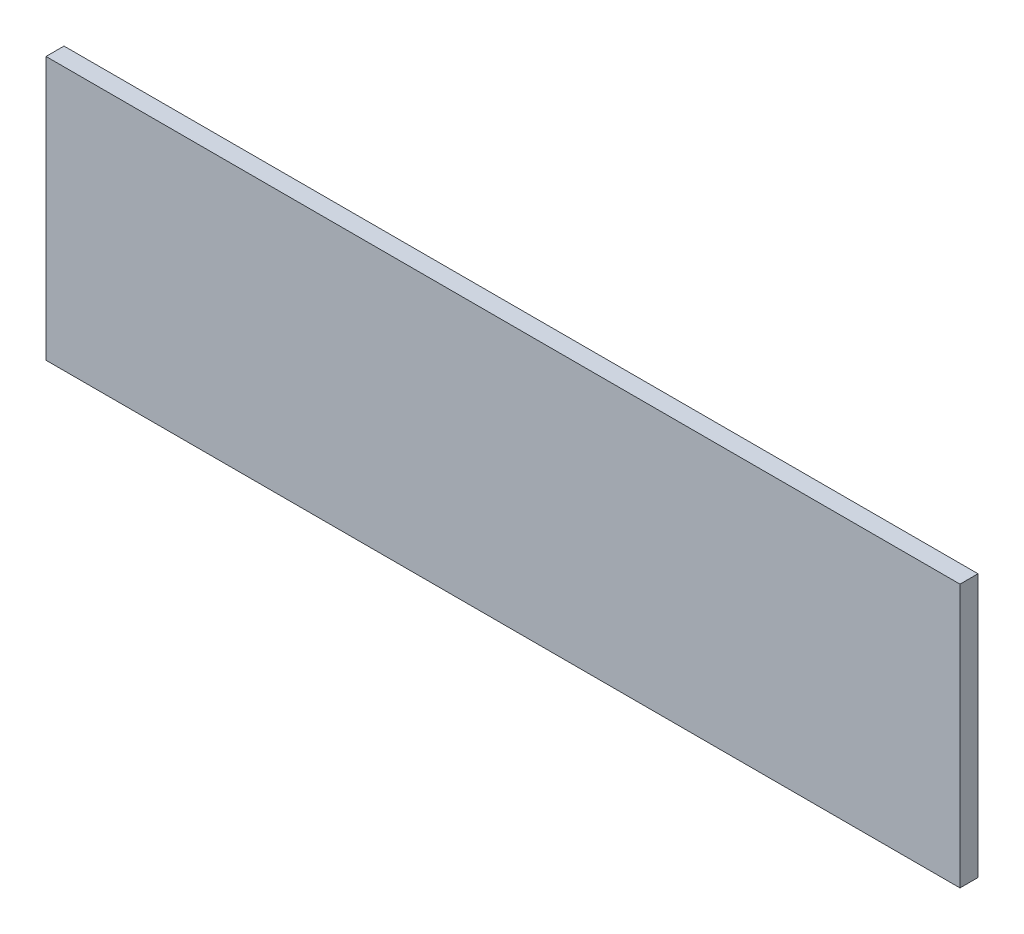
from build123d import *

# Parameters (mm, degrees)
SKETCH1_W           = 330
SKETCH1_H           = 95
BOSS_EXTRUDE1_DEPTH = 6.5


with BuildPart() as part:
    # Sketch1 → Boss-Extrude1 (new body)
    with BuildSketch(Plane.XY):
        with Locations((165, 152.5)):
            Rectangle(SKETCH1_W, SKETCH1_H)
    extrude(amount=BOSS_EXTRUDE1_DEPTH)


solid = part.part
